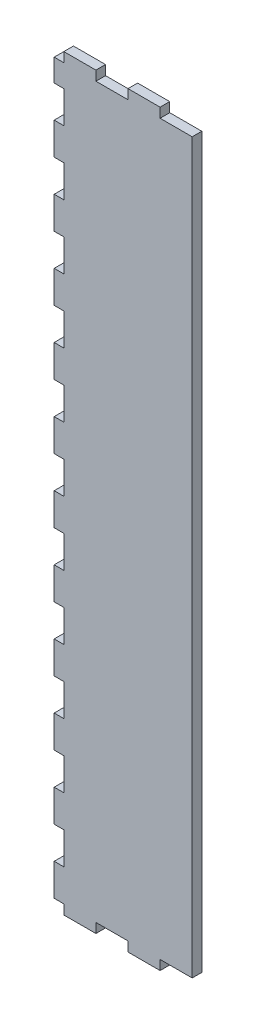
from build123d import *

# Parameters (mm, degrees)
SKETCH1_W               = 40
SKETCH1_H               = 227
BOSS_EXTRUDE1_DEPTH     = 3
SKETCH2_W               = 10
SKETCH2_H               = 3
BOSS_EXTRUDE2_DEPTH     = 3
LPATTERN1_COUNT         = 2
LPATTERN1_PITCH         = 20
SKETCH3_W               = 10
SKETCH3_H               = 3
BOSS_EXTRUDE3_DEPTH     = 3
LPATTERN2_COUNT         = 2
LPATTERN2_PITCH         = 20
SKETCH4_W               = 3
SKETCH4_H               = 10
BOSS_EXTRUDE4_DEPTH     = 3
LPATTERN3_COUNT         = 12
LPATTERN3_PITCH         = 20
ESQUISSE1_W             = 3
ESQUISSE1_H             = 3
ENL_V_MAT_EXTRU_1_DEPTH = 4


with BuildPart() as part:
    # Sketch1 → Boss-Extrude1 (new body)
    with BuildSketch(Plane.XY):
        with Locations((20, 113.5)):
            Rectangle(SKETCH1_W, SKETCH1_H)
    extrude(amount=BOSS_EXTRUDE1_DEPTH)

    # Sketch2 → Boss-Extrude2 (add)
    with BuildSketch(Plane.XZ):
        with Locations((25, 1.5)):
            Rectangle(SKETCH2_W, SKETCH2_H)
    boss_extrude2 = extrude(amount=BOSS_EXTRUDE2_DEPTH)

    # LPattern1: Boss-Extrude2 ×2
    with Locations(*[(-i * LPATTERN1_PITCH, 0, 0) for i in range(1, LPATTERN1_COUNT)]):
        add(boss_extrude2)

    # Sketch3 → Boss-Extrude3 (add)
    with BuildSketch(Plane(origin=(0, 227, 0), x_dir=(1, 0, 0), z_dir=(0, 1, 0))):
        with Locations((25, -1.5)):
            Rectangle(SKETCH3_W, SKETCH3_H)
    boss_extrude3 = extrude(amount=BOSS_EXTRUDE3_DEPTH)

    # LPattern2: Boss-Extrude3 ×2
    with Locations(*[(-i * LPATTERN2_PITCH, 0, 0) for i in range(1, LPATTERN2_COUNT)]):
        add(boss_extrude3)

    # Sketch4 → Boss-Extrude4 (add)
    with BuildSketch(Plane.ZY):
        with Locations((1.5, 5)):
            Rectangle(SKETCH4_W, SKETCH4_H)
    boss_extrude4 = extrude(amount=BOSS_EXTRUDE4_DEPTH)

    # LPattern3: Boss-Extrude4 ×12
    with Locations(*[(0, i * LPATTERN3_PITCH, 0) for i in range(1, LPATTERN3_COUNT)]):
        add(boss_extrude4)

    # Esquisse1 → Enlèv. mat.-Extru.1 (cut, through all)
    with BuildSketch(Plane.XY.offset(3)):
        with Locations((-1.5, 228.5)):
            Rectangle(ESQUISSE1_W, ESQUISSE1_H)
    extrude(amount=-ENL_V_MAT_EXTRU_1_DEPTH, mode=Mode.SUBTRACT)


solid = part.part
